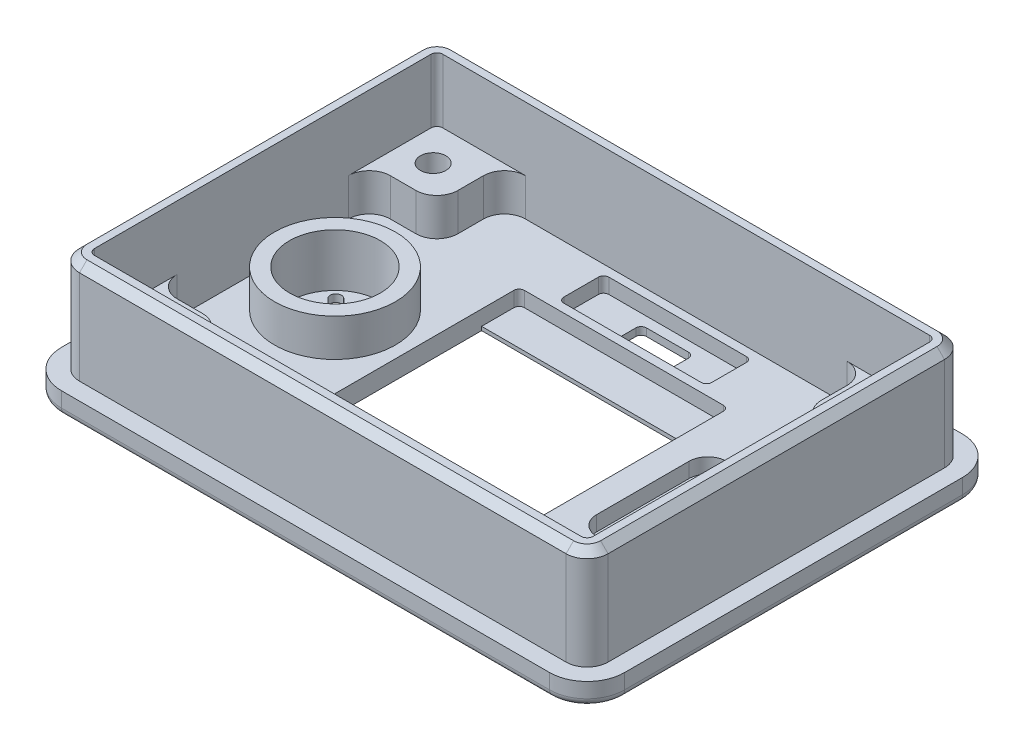
from build123d import *

# Parameters (mm, degrees)
SKETCH1_W                                           = 75
SKETCH1_H                                           = 55
BOSS_EXTRUDE1_DEPTH                                 = 3
SKETCH11_W                                          = 70.4
SKETCH11_H                                          = 50.4
BOSS_EXTRUDE2_DEPTH                                 = 13.5
SKETCH11_3_W                                        = 9
SKETCH11_3_H                                        = 9
BOSS_EXTRUDE4_DEPTH                                 = 5
CUT_EXTRUDE1_DEPTH                                  = 4
SKETCH2_4_W                                         = 27.9
SKETCH2_4_H                                         = 5
CUT_EXTRUDE2_DEPTH                                  = 2
FILLET1_R                                           = 5
FILLET2_R                                           = 2.8
FILLET3_R                                           = 1
SKETCH13_R                                          = 8.05
SKETCH13_R_2                                        = 6.05
BOSS_EXTRUDE3_DEPTH                                 = 5
SKETCH15_R                                          = 6.05
CUT_EXTRUDE4_DEPTH                                  = 2
SKETCH14_R                                          = 1.35
CUT_EXTRUDE3_DEPTH                                  = 4
CUT_EXTRUDE5_DEPTH                                  = 4
CUT_EXTRUDE6_DEPTH                                  = 2
SKETCH17_W                                          = 19.7
SKETCH17_H                                          = 6
CUT_EXTRUDE7_DEPTH                                  = 2
SKETCH18_W                                          = 7
SKETCH18_H                                          = 3.3
CUT_EXTRUDE8_DEPTH                                  = 2
CHAMFER1_SIZE                                       = 0.5
FILLET4_R                                           = 0.7
FILLET5_R                                           = 0.8
CHAMFER2_SIZE                                       = 1
CBORE_FOR_M3_HEX_SOCKET_HEAD_CAP_SCREW1_D           = 3.4
CBORE_FOR_M3_HEX_SOCKET_HEAD_CAP_SCREW1_CBORE_D     = 5.7
CBORE_FOR_M3_HEX_SOCKET_HEAD_CAP_SCREW1_CBORE_DEPTH = 3.1


with BuildPart() as part:
    # Sketch1 → Boss-Extrude1 (new body)
    with BuildSketch(Plane(origin=(0, 0, 0), x_dir=(1, 0, 0), z_dir=(0, 1, 0))):
        Rectangle(SKETCH1_W, SKETCH1_H)
    extrude(amount=BOSS_EXTRUDE1_DEPTH)

    # Sketch11 → Boss-Extrude2 (add)
    with BuildSketch(Plane(origin=(0, 3, 0), x_dir=(1, 0, 0), z_dir=(0, 1, 0))):
        Rectangle(SKETCH11_W, SKETCH11_H)
        Polygon((24.2, 23.2), (33.2, 23.2), (33.2, 14.2), (33.2, -14.2), (33.2, -23.2), (24.2, -23.2), (-24.2, -23.2), (-33.2, -23.2), (-33.2, -14.2), (-33.2, 14.2), (-33.2, 23.2), (-24.2, 23.2), align=None, mode=Mode.SUBTRACT)
    extrude(amount=BOSS_EXTRUDE2_DEPTH)

    # Sketch11_3 → Boss-Extrude4 (add)
    with BuildSketch(Plane(origin=(0, 3, 0), x_dir=(1, 0, 0), z_dir=(0, 1, 0))):
        with Locations((28.7, 18.7)):
            Rectangle(SKETCH11_3_W, SKETCH11_3_H)
        with Locations((-28.7, 18.7)):
            Rectangle(SKETCH11_3_W, SKETCH11_3_H)
        with Locations((28.7, -18.7)):
            Rectangle(SKETCH11_3_W, SKETCH11_3_H)
        with Locations((-28.7, -18.7)):
            Rectangle(SKETCH11_3_W, SKETCH11_3_H)
    extrude(amount=BOSS_EXTRUDE4_DEPTH)

    # Sketch2 → Cut-Extrude1 (cut, through all)
    with BuildSketch(Plane(origin=(0, 3, 0), x_dir=(1, 0, 0), z_dir=(0, 1, 0))):
        Polygon((6.75, -9.9), (6.75, -12.3), (-6.75, -12.3), (-6.75, -9.9), (-13.95, -9.9), (-13.95, 9.9), (13.95, 9.9), (13.95, -9.9), align=None)
    extrude(amount=-CUT_EXTRUDE1_DEPTH, mode=Mode.SUBTRACT)

    # Sketch2_4 → Cut-Extrude2 (cut)
    with BuildSketch(Plane(origin=(0, 3, 0), x_dir=(1, 0, 0), z_dir=(0, 1, 0))):
        with Locations((0, 12.4)):
            Rectangle(SKETCH2_4_W, SKETCH2_4_H)
        Polygon((13.95, -9.9), (6.75, -9.9), (6.75, -12.3), (-6.75, -12.3), (-6.75, -9.9), (-13.95, -9.9), (-13.95, -14.9), (13.95, -14.9), align=None)
    extrude(amount=-CUT_EXTRUDE2_DEPTH, mode=Mode.SUBTRACT)

    # Fillet1
    fillet1_edges = [part.edges().sort_by_distance(p)[0] for p in [
        (37.5, 1.5, 27.5),
        (-37.5, 1.5, 27.5),
        (-37.5, 1.5, -27.5),
        (37.5, 1.5, -27.5),
    ]]
    fillet(fillet1_edges, radius=FILLET1_R)

    # Fillet2
    fillet2_edges = [part.edges().sort_by_distance(p)[0] for p in [
        (35.2, 9.75, 25.2),
        (35.2, 9.75, -25.2),
        (-35.2, 9.75, -25.2),
        (-35.2, 9.75, 25.2),
        (33.2, 5.5, 14.2),
        (24.2, 5.5, 14.2),
        (24.2, 5.5, 23.2),
        (-24.2, 5.5, 23.2),
        (-24.2, 5.5, 14.2),
        (-33.2, 5.5, 14.2),
        (-24.2, 5.5, -23.2),
        (-33.2, 5.5, -14.2),
        (-24.2, 5.5, -14.2),
        (24.2, 5.5, -23.2),
        (24.2, 5.5, -14.2),
        (33.2, 5.5, -14.2),
    ]]
    fillet(fillet2_edges, radius=FILLET2_R)

    # Fillet3
    fillet3_edges = [part.edges().sort_by_distance(p)[0] for p in [
        (0, 0, 27.5),
        (37.5, 0, 0),
        (-37.5, 0, 0),
        (0, 0, -27.5),
        (-36.035533906, 0, -26.035533906),
        (36.035533906, 0, -26.035533906),
        (36.035533906, 0, 26.035533906),
        (-36.035533906, 0, 26.035533906),
    ]]
    fillet(fillet3_edges, radius=FILLET3_R)

    # Sketch13 → Boss-Extrude3 (add)
    with BuildSketch(Plane(origin=(0, 3, 0), x_dir=(1, 0, 0), z_dir=(0, 1, 0))):
        with Locations((-23.575, 0)):
            Circle(SKETCH13_R)
        with Locations((-23.575, 0)):
            Circle(SKETCH13_R_2, mode=Mode.SUBTRACT)
    extrude(amount=BOSS_EXTRUDE3_DEPTH)

    # Sketch15 → Cut-Extrude4 (cut)
    with BuildSketch(Plane(origin=(0, 3, 0), x_dir=(1, 0, 0), z_dir=(0, 1, 0))):
        with Locations((-23.575, 0)):
            Circle(SKETCH15_R)
    extrude(amount=-CUT_EXTRUDE4_DEPTH, mode=Mode.SUBTRACT)

    # Sketch14 → Cut-Extrude3 (cut, through all)
    with BuildSketch(Plane(origin=(0, 3, 0), x_dir=(1, 0, 0), z_dir=(0, 1, 0))):
        with Locations((-23.575, 0)):
            Circle(SKETCH14_R)
        with BuildLine():
            Line((-26.325, -0.75), (-28.325, -0.75))
            ThreePointArc((-28.325, -0.75), (-29.075, 0), (-28.325, 0.75))
            Line((-28.325, 0.75), (-26.325, 0.75))
            ThreePointArc((-26.325, 0.75), (-25.575, 0), (-26.325, -0.75))
        make_face()
        with BuildLine():
            Line((-25.993232529, 1.469669914), (-27.407446092, 2.883883476))
            ThreePointArc((-27.407446092, 2.883883476), (-27.407446092, 3.944543648), (-26.34678592, 3.944543648))
            Line((-26.34678592, 3.944543648), (-24.932572357, 2.530330086))
            ThreePointArc((-24.932572357, 2.530330086), (-24.932572357, 1.469669914), (-25.993232529, 1.469669914))
        make_face()
        with BuildLine():
            Line((-24.932572357, -2.530330086), (-26.34678592, -3.944543648))
            ThreePointArc((-26.34678592, -3.944543648), (-27.407446092, -3.944543648), (-27.407446092, -2.883883476))
            Line((-27.407446092, -2.883883476), (-25.993232529, -1.469669914))
            ThreePointArc((-25.993232529, -1.469669914), (-24.932572357, -1.469669914), (-24.932572357, -2.530330086))
        make_face()
        with BuildLine():
            Line((-21.156767471, 1.469669914), (-19.742553908, 2.883883476))
            ThreePointArc((-19.742553908, 2.883883476), (-19.742553908, 3.944543648), (-20.80321408, 3.944543648))
            Line((-20.80321408, 3.944543648), (-22.217427643, 2.530330086))
            ThreePointArc((-22.217427643, 2.530330086), (-22.217427643, 1.469669914), (-21.156767471, 1.469669914))
        make_face()
        with BuildLine():
            Line((-20.825, -0.75), (-18.825, -0.75))
            ThreePointArc((-18.825, -0.75), (-18.075, 0), (-18.825, 0.75))
            Line((-18.825, 0.75), (-20.825, 0.75))
            ThreePointArc((-20.825, 0.75), (-21.575, 0), (-20.825, -0.75))
        make_face()
        with BuildLine():
            Line((-22.217427643, -2.530330086), (-20.80321408, -3.944543648))
            ThreePointArc((-20.80321408, -3.944543648), (-19.742553908, -3.944543648), (-19.742553908, -2.883883476))
            Line((-19.742553908, -2.883883476), (-21.156767471, -1.469669914))
            ThreePointArc((-21.156767471, -1.469669914), (-22.217427643, -1.469669914), (-22.217427643, -2.530330086))
        make_face()
    extrude(amount=-CUT_EXTRUDE3_DEPTH, mode=Mode.SUBTRACT)

    # Sketch16 → Cut-Extrude5 (cut, through all)
    with BuildSketch(Plane(origin=(0, 3, 0), x_dir=(1, 0, 0), z_dir=(0, 1, 0))):
        with BuildLine():
            Line((19.925, -7.65), (27.225, -7.65))
            ThreePointArc((27.225, -7.65), (28.285660172, -7.210660172), (28.725, -6.15))
            Line((28.725, -6.15), (28.725, 6.15))
            ThreePointArc((28.725, 6.15), (28.285660172, 7.210660172), (27.225, 7.65))
            Line((27.225, 7.65), (19.925, 7.65))
            ThreePointArc((19.925, 7.65), (18.864339828, 7.210660172), (18.425, 6.15))
            Line((18.425, 6.15), (18.425, -6.15))
            ThreePointArc((18.425, -6.15), (18.864339828, -7.210660172), (19.925, -7.65))
        make_face()
    extrude(amount=-CUT_EXTRUDE5_DEPTH, mode=Mode.SUBTRACT)

    # Sketch16_3 → Cut-Extrude6 (cut)
    with BuildSketch(Plane(origin=(0, 3, 0), x_dir=(1, 0, 0), z_dir=(0, 1, 0))):
        with BuildLine():
            Line((19.925, 8.65), (27.225, 8.65))
            ThreePointArc((27.225, 8.65), (28.992766953, 7.917766953), (29.725, 6.15))
            Line((29.725, 6.15), (29.725, -6.15))
            ThreePointArc((29.725, -6.15), (28.992766953, -7.917766953), (27.225, -8.65))
            Line((27.225, -8.65), (19.925, -8.65))
            ThreePointArc((19.925, -8.65), (18.157233047, -7.917766953), (17.425, -6.15))
            Line((17.425, -6.15), (17.425, 6.15))
            ThreePointArc((17.425, 6.15), (18.157233047, 7.917766953), (19.925, 8.65))
        make_face()
        with BuildLine():
            Line((19.925, -7.65), (27.225, -7.65))
            ThreePointArc((27.225, -7.65), (28.285660172, -7.210660172), (28.725, -6.15))
            Line((28.725, -6.15), (28.725, 6.15))
            ThreePointArc((28.725, 6.15), (28.285660172, 7.210660172), (27.225, 7.65))
            Line((27.225, 7.65), (19.925, 7.65))
            ThreePointArc((19.925, 7.65), (18.864339828, 7.210660172), (18.425, 6.15))
            Line((18.425, 6.15), (18.425, -6.15))
            ThreePointArc((18.425, -6.15), (18.864339828, -7.210660172), (19.925, -7.65))
        make_face(mode=Mode.SUBTRACT)
    extrude(amount=-CUT_EXTRUDE6_DEPTH, mode=Mode.SUBTRACT)

    # Sketch17 → Cut-Extrude7 (cut)
    with BuildSketch(Plane(origin=(0, 3, 0), x_dir=(1, 0, 0), z_dir=(0, 1, 0))):
        with Locations((0, 19.05)):
            Rectangle(SKETCH17_W, SKETCH17_H)
    extrude(amount=-CUT_EXTRUDE7_DEPTH, mode=Mode.SUBTRACT)

    # Sketch18 → Cut-Extrude8 (cut, through all)
    with BuildSketch(Plane(origin=(0, 1, 0), x_dir=(1, 0, 0), z_dir=(0, 1, 0))):
        with Locations((0, 19.05)):
            Rectangle(SKETCH18_W, SKETCH18_H)
    extrude(amount=-CUT_EXTRUDE8_DEPTH, mode=Mode.SUBTRACT)

    # Chamfer1
    chamfer1_edges = [part.edges().sort_by_distance(p)[0] for p in [
        (0, 0, 12.3),
        (-6.75, 0, 11.1),
        (-10.35, 0, 9.9),
        (13.95, 0, 0),
        (10.35, 0, 9.9),
        (6.75, 0, 11.1),
        (-13.95, 0, 0),
        (0, 0, -9.9),
        (28.725, 0, 0),
        (28.285660172, 0, 7.210660172),
        (23.575, 0, 7.65),
        (18.864339828, 0, 7.210660172),
        (18.425, 0, 0),
        (18.864339828, 0, -7.210660172),
        (23.575, 0, -7.65),
        (28.285660172, 0, -7.210660172),
    ]]
    chamfer(chamfer1_edges, length=CHAMFER1_SIZE)

    # Fillet4
    fillet4_edges = [part.edges().sort_by_distance(p)[0] for p in [
        (13.95, 2, -14.9),
        (-13.95, 2, -14.9),
        (-13.95, 2, 14.9),
        (13.95, 2, 14.9),
        (-9.85, 2, -22.05),
        (-9.85, 2, -16.05),
        (9.85, 2, -16.05),
        (9.85, 2, -22.05),
        (3.5, 0.5, -20.7),
        (3.5, 0.5, -17.4),
        (-3.5, 0.5, -17.4),
        (-3.5, 0.5, -20.7),
    ]]
    fillet(fillet4_edges, radius=FILLET4_R)

    # Fillet5
    fillet5_edges = [part.edges().sort_by_distance(p)[0] for p in [
        (33.2, 12.25, -23.2),
        (33.2, 12.25, 23.2),
        (-33.2, 12.25, 23.2),
        (-33.2, 12.25, -23.2),
    ]]
    fillet(fillet5_edges, radius=FILLET5_R)

    # Chamfer2
    chamfer2_edges = [part.edges().sort_by_distance(p)[0] for p in [
        (-35.2, 16.5, 0),
        (0, 16.5, -25.2),
        (35.2, 16.5, 0),
        (0, 16.5, 25.2),
        (34.379898987, 16.5, -24.379898987),
        (34.379898987, 16.5, 24.379898987),
        (-34.379898987, 16.5, 24.379898987),
        (-34.379898987, 16.5, -24.379898987),
    ]]
    chamfer(chamfer2_edges, length=CHAMFER2_SIZE)

    # CBORE for M3 Hex Socket Head Cap Screw1 (through all)
    with Locations(Plane.XZ):
        with Locations((-29, -18.5), (0, 0), (-29, 18.5), (29, 18.5), (29, -18.5)):
            CounterBoreHole(CBORE_FOR_M3_HEX_SOCKET_HEAD_CAP_SCREW1_D / 2, CBORE_FOR_M3_HEX_SOCKET_HEAD_CAP_SCREW1_CBORE_D / 2, CBORE_FOR_M3_HEX_SOCKET_HEAD_CAP_SCREW1_CBORE_DEPTH)


solid = part.part
